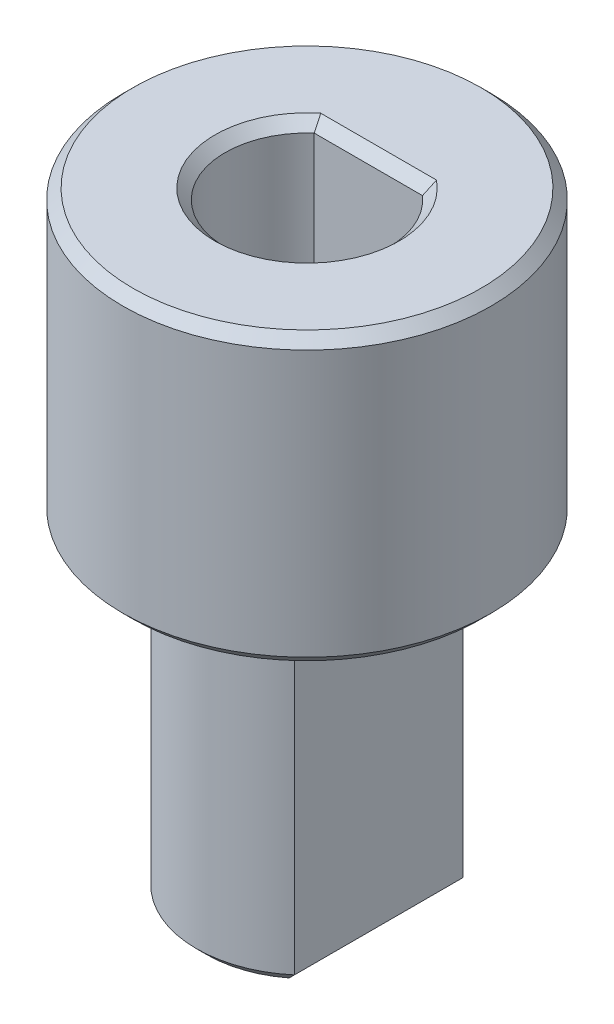
from build123d import *

# Parameters (mm, degrees)
BOSS_EXTRUDE1_DEPTH = 8
SKETCH2_R           = 4.5
BOSS_EXTRUDE2_DEPTH = 7
CUT_EXTRUDE1_DEPTH  = 5.5
FILLET1_R           = 0.5
CHAMFER1_SIZE       = 0.25


with BuildPart() as part:
    # Sketch1 → Boss-Extrude1 (new body)
    with BuildSketch(Plane(origin=(0, 0, 0), x_dir=(1, 0, 0), z_dir=(0, 1, 0))):
        with BuildLine():
            Line((-1.75, 2.056088519), (-1.75, -2.056088519))
            ThreePointArc((-1.75, -2.056088519), (0, -2.7), (1.75, -2.056088519))
            Line((1.75, -2.056088519), (1.75, 2.056088519))
            ThreePointArc((1.75, 2.056088519), (0, 2.7), (-1.75, 2.056088519))
        make_face()
    extrude(amount=BOSS_EXTRUDE1_DEPTH)

    # Sketch2 → Boss-Extrude2 (add)
    with BuildSketch(Plane(origin=(0, 8, 0), x_dir=(1, 0, 0), z_dir=(0, 1, 0))):
        Circle(SKETCH2_R)
    extrude(amount=BOSS_EXTRUDE2_DEPTH)

    # Sketch3 → Cut-Extrude1 (cut)
    with BuildSketch(Plane(origin=(0, 15, 0), x_dir=(1, 0, 0), z_dir=(0, 1, 0))):
        with BuildLine():
            Line((-1.322875656, 1.5), (1.322875656, 1.5))
            ThreePointArc((1.322875656, 1.5), (0, -2), (-1.322875656, 1.5))
        make_face()
    extrude(amount=-CUT_EXTRUDE1_DEPTH, mode=Mode.SUBTRACT)

    # Fillet1
    fillet1_edges = [part.edges().sort_by_distance(p)[0] for p in [
        (0, 8, 2.7),
        (1.75, 8, 0),
        (0, 8, -2.7),
        (-1.75, 8, 0),
    ]]
    fillet(fillet1_edges, radius=FILLET1_R)

    # Chamfer1
    chamfer1_edges = [part.edges().sort_by_distance(p)[0] for p in [
        (-4.5, 8, 0),
        (-4.5, 15, 0),
        (0, 15, 2),
        (0, 15, -1.5),
        (1.75, 0, 0),
        (0, 0, 2.7),
        (-1.75, 0, 0),
        (0, 0, -2.7),
    ]]
    chamfer(chamfer1_edges, length=CHAMFER1_SIZE)


solid = part.part
